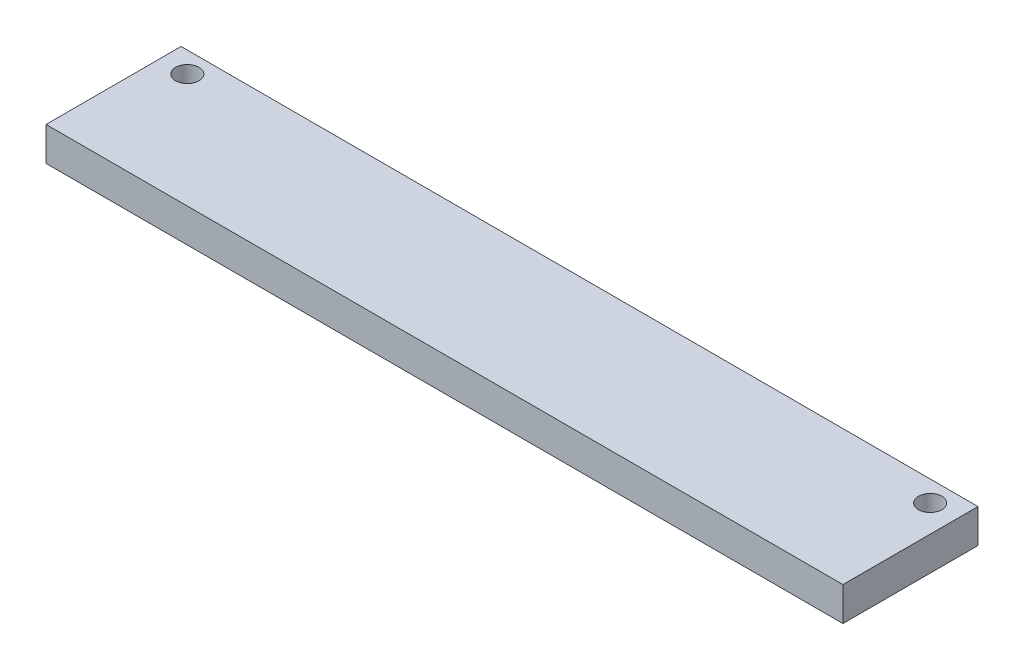
from build123d import *

# Parameters (mm, degrees)
ESBO_O1_W                = 74.93
ESBO_O1_H                = 12.7
RESSALTO_EXTRUS_O1_DEPTH = 3.175
ESBO_O2_R                = 1.1
CORTE_EXTRUS_O1_DEPTH    = 12.175


with BuildPart() as part:
    # Esboço1 → Ressalto-extrusão1 (new body)
    with BuildSketch(Plane(origin=(0, 0, 0), x_dir=(1, 0, 0), z_dir=(0, 1, 0))):
        with Locations((-7.430597687, -0.654986873)):
            Rectangle(ESBO_O1_W, ESBO_O1_H)
    extrude(amount=RESSALTO_EXTRUS_O1_DEPTH)

    # Esboço2 → Corte-extrusão1 (cut)
    with BuildSketch(Plane.XZ):
        with Locations((27.494402313, -3.739192561)):
            Circle(ESBO_O2_R)
        with Locations((-42.355597687, -3.739192561)):
            Circle(ESBO_O2_R)
    extrude(amount=-CORTE_EXTRUS_O1_DEPTH, mode=Mode.SUBTRACT)


solid = part.part
